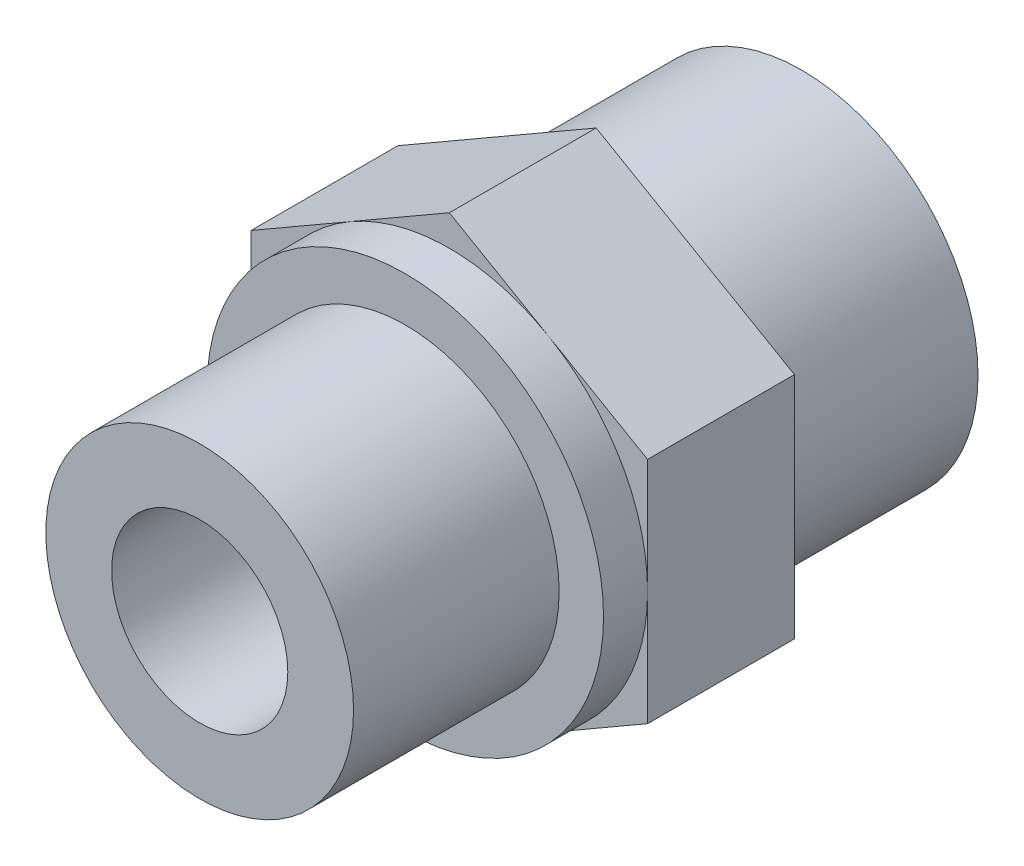
from build123d import *

# Parameters (mm, degrees)
BASE_EXTRUDE_DEPTH  = 10
SKETCH2_R           = 13.5
BOSS_EXTRUDE1_DEPTH = 3
SKETCH3_R           = 10.4775
BOSS_EXTRUDE2_DEPTH = 14
SKETCH4_R           = 12
BOSS_EXTRUDE3_DEPTH = 14
SKETCH5_R           = 6
CUT_EXTRUDE1_DEPTH  = 42


with BuildPart() as part:
    # Sketch1 → Base-Extrude (new body)
    with BuildSketch(Plane.XY):
        Polygon((0, 15.588457268), (-13.5, 7.794228634), (-13.5, -7.794228634), (0, -15.588457268), (13.5, -7.794228634), (13.5, 7.794228634), align=None)
    extrude(amount=BASE_EXTRUDE_DEPTH)

    # Sketch2 → Boss-Extrude1 (add)
    with BuildSketch(Plane.XY.offset(10)):
        Circle(SKETCH2_R)
    extrude(amount=BOSS_EXTRUDE1_DEPTH)

    # Sketch3 → Boss-Extrude2 (add)
    with BuildSketch(Plane.XY.offset(13)):
        Circle(SKETCH3_R)
    extrude(amount=BOSS_EXTRUDE2_DEPTH)

    # Sketch4 → Boss-Extrude3 (add)
    with BuildSketch(Plane(origin=(0, 0, 0), x_dir=(-1, 0, 0), z_dir=(0, 0, -1))):
        Circle(SKETCH4_R)
    extrude(amount=BOSS_EXTRUDE3_DEPTH)

    # Sketch5 → Cut-Extrude1 (cut, through all)
    with BuildSketch(Plane.XY.offset(27)):
        Circle(SKETCH5_R)
    extrude(amount=-CUT_EXTRUDE1_DEPTH, mode=Mode.SUBTRACT)

    # Sketch7 → Cut-Revolve1 (revolve, cut)
    with BuildSketch(Plane(origin=(0, 0, 0), x_dir=(0, 0, -1), z_dir=(1, 0, 0))):
        Polygon((14, 0), (14, 9.15), (8.589675374, 8), (5.5, 8), (5.5, 0), align=None)
    revolve(axis=Axis((0, 0, 0), (0, 0, -1)), mode=Mode.SUBTRACT)


solid = part.part
